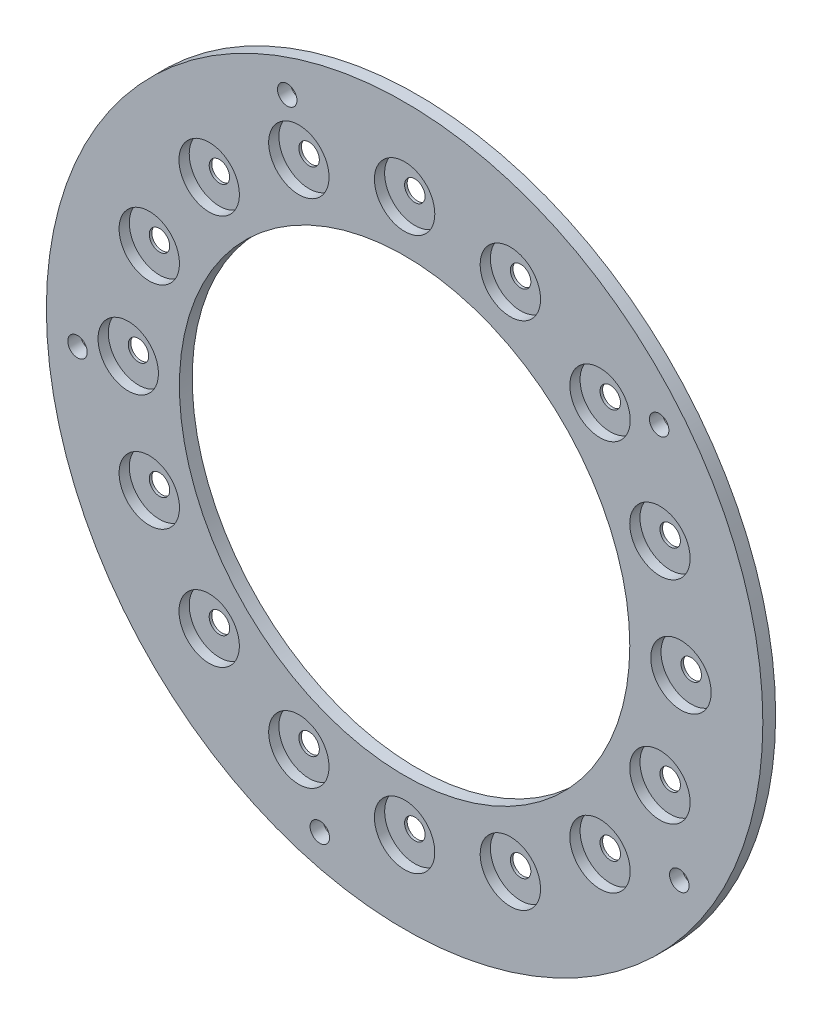
from build123d import *

# Parameters (mm, degrees)
SKETCH1_R           = 35
BOSS_EXTRUDE1_DEPTH = 1.55
SKETCH2_R           = 22
CUT_EXTRUDE1_DEPTH  = 50.521737651
SKETCH3_R           = 2.95
CUT_EXTRUDE6_DEPTH  = 1
SKETCH5_R           = 1
CUT_EXTRUDE7_DEPTH  = 50.521737651
MOVE_FACE1_BY       = 0.3
CIRPATTERN2_COUNT   = 16
SKETCH6_R           = 0.95
CUT_EXTRUDE8_DEPTH  = 50.513255801
CIRPATTERN3_COUNT   = 5


with BuildPart() as part:
    # Sketch1 → Boss-Extrude1 (new body)
    with BuildSketch(Plane.XY):
        Circle(SKETCH1_R)
    extrude(amount=BOSS_EXTRUDE1_DEPTH)

    # Sketch2 → Cut-Extrude1 (cut, through all)
    with BuildSketch(Plane.XY.offset(1.55)):
        Circle(SKETCH2_R)
    extrude(amount=-CUT_EXTRUDE1_DEPTH, mode=Mode.SUBTRACT)

    # Sketch3 → Cut-Extrude6 (cut)
    with BuildSketch(Plane.XY.offset(1.55)):
        with Locations((0, 27)):
            Circle(SKETCH3_R)
    cut_extrude6 = extrude(amount=-CUT_EXTRUDE6_DEPTH, mode=Mode.SUBTRACT)

    # Sketch5 → Cut-Extrude7 (cut, through all)
    with BuildSketch(Plane.XY.offset(1.55)):
        with Locations((0, 27)):
            Circle(SKETCH5_R)
    cut_extrude7 = extrude(amount=-CUT_EXTRUDE7_DEPTH, mode=Mode.SUBTRACT)

    # Move Face1: a face moved inward by 0.3
    extrude(part.faces().sort_by_distance((0, -28, 0))[0], amount=MOVE_FACE1_BY, dir=(0, 0, 1), mode=Mode.SUBTRACT)

    # CirPattern2: Cut-Extrude6, Cut-Extrude7 ×16 about axis
    cirpattern2_axis = Axis((0, 0, -88.99), (0, 0, 1))
    add([cut_extrude6.rotate(cirpattern2_axis, i * 360 / CIRPATTERN2_COUNT) for i in range(1, CIRPATTERN2_COUNT)], mode=Mode.SUBTRACT)
    add([cut_extrude7.rotate(cirpattern2_axis, i * 360 / CIRPATTERN2_COUNT) for i in range(1, CIRPATTERN2_COUNT)], mode=Mode.SUBTRACT)

    # Sketch6 → Cut-Extrude8 (cut, through all)
    with BuildSketch(Plane(origin=(0, 0, 0.3), x_dir=(-1, 0, 0), z_dir=(0, 0, -1))):
        with Locations((11.467774385, 29.874573648)):
            Circle(SKETCH6_R)
    cut_extrude8 = extrude(amount=-CUT_EXTRUDE8_DEPTH, mode=Mode.SUBTRACT)

    # CirPattern3: Cut-Extrude8 ×5 about axis
    cirpattern3_axis = Axis((0, 0, -88.99), (0, 0, 1))
    for i in range(1, CIRPATTERN3_COUNT):
        add(cut_extrude8.rotate(cirpattern3_axis, i * 360 / CIRPATTERN3_COUNT), mode=Mode.SUBTRACT)


solid = part.part
